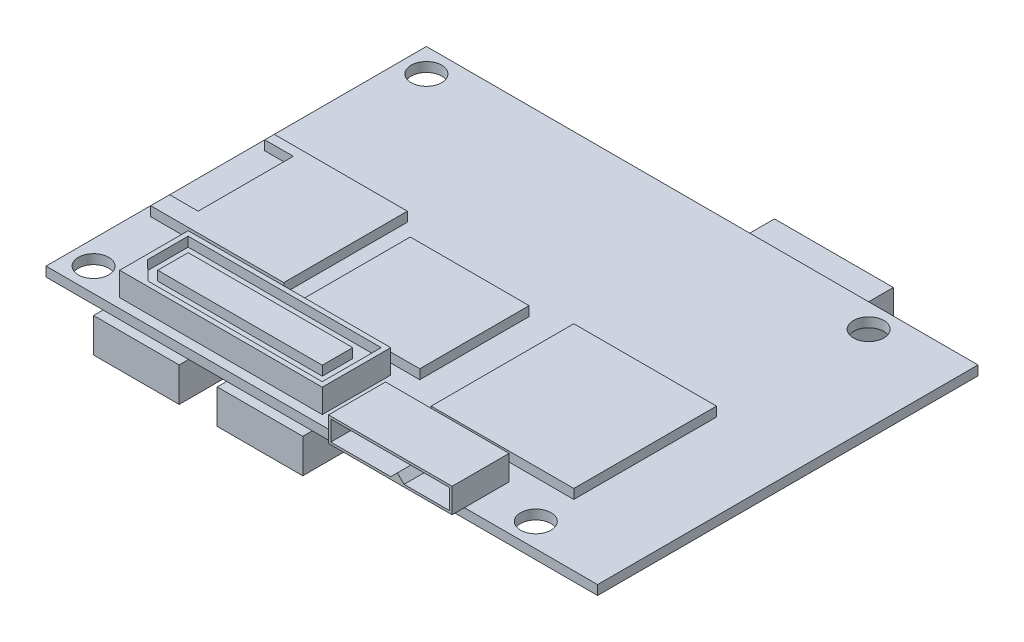
from build123d import *

# Parameters (mm, degrees)
SKETCH1_W            = 58
SKETCH1_H            = 40
BOSS_EXTRUDE1_DEPTH  = 1
SKETCH2_W            = 14
SKETCH2_H            = 13
BOSS_EXTRUDE2_DEPTH  = 1
SKETCH3_W            = 3
SKETCH3_H            = 10
CUT_EXTRUDE1_DEPTH   = 1
SKETCH4_W            = 12.5
SKETCH4_H            = 11.5
SKETCH4_W_2          = 15
SKETCH4_H_2          = 15
BOSS_EXTRUDE3_DEPTH  = 1
SKETCH5_W            = 13
SKETCH5_H            = 6
BOSS_EXTRUDE4_DEPTH  = 2.6
CUT_EXTRUDE2_DEPTH   = 5
SKETCH7_W            = 21.3
SKETCH7_H            = 7.2
BOSS_EXTRUDE5_DEPTH  = 2.5
SKETCH8_W            = 17.3
SKETCH8_H            = 3.2
CUT_EXTRUDE3_DEPTH   = 1
SKETCH9_R            = 1.6
CUT_EXTRUDE4_DEPTH   = 2
SKETCH10_W           = 9
SKETCH10_H           = 5
BOSS_EXTRUDE6_DEPTH  = 3.6
SKETCH11_W           = 12.5
SKETCH11_H           = 6.25
BOSS_EXTRUDE7_DEPTH  = 5
SKETCH12_W           = 10
SKETCH12_H           = 10
BOSS_EXTRUDE8_DEPTH  = 2.5
SKETCH13_R           = 1
SKETCH13_R_2         = 0.8
BOSS_EXTRUDE9_DEPTH  = 1
SKETCH14_R           = 0.15
BOSS_EXTRUDE10_DEPTH = 1


with BuildPart() as part:
    # Sketch1 → Boss-Extrude1 (new body)
    with BuildSketch(Plane(origin=(0, 0, 0), x_dir=(1, 0, 0), z_dir=(0, 1, 0))):
        Rectangle(SKETCH1_W, SKETCH1_H)
    extrude(amount=BOSS_EXTRUDE1_DEPTH)

    # Sketch2 → Boss-Extrude2 (add)
    with BuildSketch(Plane(origin=(0, 1, 0), x_dir=(1, 0, 0), z_dir=(0, 1, 0))):
        with Locations((-21, -3.5)):
            Rectangle(SKETCH2_W, SKETCH2_H)
    extrude(amount=BOSS_EXTRUDE2_DEPTH)

    # Sketch3 → Cut-Extrude1 (cut)
    with BuildSketch(Plane(origin=(0, 2, 0), x_dir=(1, 0, 0), z_dir=(0, 1, 0))):
        with Locations((-26.5, -3)):
            Rectangle(SKETCH3_W, SKETCH3_H)
    extrude(amount=-CUT_EXTRUDE1_DEPTH, mode=Mode.SUBTRACT)

    # Sketch4 → Boss-Extrude3 (add)
    with BuildSketch(Plane(origin=(0, 1, 0), x_dir=(1, 0, 0), z_dir=(0, 1, 0))):
        with Locations((-5.25, -4.95)):
            Rectangle(SKETCH4_W, SKETCH4_H)
        with Locations((12.5, -6)):
            Rectangle(SKETCH4_W_2, SKETCH4_H_2)
    extrude(amount=BOSS_EXTRUDE3_DEPTH)

    # Sketch5 → Boss-Extrude4 (add)
    with BuildSketch(Plane(origin=(0, 1, 0), x_dir=(1, 0, 0), z_dir=(0, 1, 0))):
        with Locations((8.5, -18.3)):
            Rectangle(SKETCH5_W, SKETCH5_H)
    extrude(amount=BOSS_EXTRUDE4_DEPTH)

    # Sketch6 → Cut-Extrude2 (cut)
    with BuildSketch(Plane.XY.offset(21.3)):
        Polygon((2.25, 3.35), (14.75, 3.35), (14.75, 1.25), (9.95, 1.25), (9.25, 1.95), (8.55, 1.25), (2.25, 1.25), align=None)
    extrude(amount=-CUT_EXTRUDE2_DEPTH, mode=Mode.SUBTRACT)

    # Sketch7 → Boss-Extrude5 (add)
    with BuildSketch(Plane(origin=(0, 1, 0), x_dir=(1, 0, 0), z_dir=(0, 1, 0))):
        with Locations((-11.6, -15.4)):
            Rectangle(SKETCH7_W, SKETCH7_H)
    extrude(amount=BOSS_EXTRUDE5_DEPTH)

    # Sketch8 → Cut-Extrude3 (cut)
    with BuildSketch(Plane(origin=(0, 3.5, 0), x_dir=(1, 0, 0), z_dir=(0, 1, 0))):
        Polygon((-21.75, -12.3), (-21.75, -16.586355197), (-19.749371343, -18.5), (-1.45, -18.5), (-1.45, -12.3), align=None)
        with Locations((-11.6, -15.4)):
            Rectangle(SKETCH8_W, SKETCH8_H, mode=Mode.SUBTRACT)
    extrude(amount=-CUT_EXTRUDE3_DEPTH, mode=Mode.SUBTRACT)

    # Sketch9 → Cut-Extrude4 (cut, through all)
    with BuildSketch(Plane(origin=(0, 1, 0), x_dir=(1, 0, 0), z_dir=(0, 1, 0))):
        with Locations((-26.5, 17.5)):
            Circle(SKETCH9_R)
        with Locations((20, 17.5)):
            Circle(SKETCH9_R)
        with Locations((20, -17.5)):
            Circle(SKETCH9_R)
        with Locations((-26.5, -17.5)):
            Circle(SKETCH9_R)
    extrude(amount=-CUT_EXTRUDE4_DEPTH, mode=Mode.SUBTRACT)

    # Sketch10 → Boss-Extrude6 (add)
    with BuildSketch(Plane.XZ):
        with Locations((-18.5, 18.5)):
            Rectangle(SKETCH10_W, SKETCH10_H)
        with Locations((-5.5, 18.5)):
            Rectangle(SKETCH10_W, SKETCH10_H)
        with Locations((-17.8, -18.5)):
            Rectangle(SKETCH10_W, SKETCH10_H)
        with Locations((-4.8, -18.5)):
            Rectangle(SKETCH10_W, SKETCH10_H)
    extrude(amount=BOSS_EXTRUDE6_DEPTH)

    # Sketch11 → Boss-Extrude7 (add)
    with BuildSketch(Plane.XZ):
        with Locations((10.25, -20.475)):
            Rectangle(SKETCH11_W, SKETCH11_H)
    extrude(amount=BOSS_EXTRUDE7_DEPTH)

    # Sketch12 → Boss-Extrude8 (add)
    with BuildSketch(Plane.XZ):
        with Locations((-18, 6.5)):
            Rectangle(SKETCH12_W, SKETCH12_H)
    extrude(amount=BOSS_EXTRUDE8_DEPTH)

    # Sketch13 → Boss-Extrude9 (add)
    with BuildSketch(Plane.XZ):
        with Locations((-26.5, 12.5)):
            Circle(SKETCH13_R)
        with Locations((-26.5, 12.5)):
            Circle(SKETCH13_R_2, mode=Mode.SUBTRACT)
        with Locations((-26.5, 4)):
            Circle(SKETCH13_R)
        with Locations((-26.5, 4)):
            Circle(SKETCH13_R_2, mode=Mode.SUBTRACT)
        with Locations((-26.5, -3.5)):
            Circle(SKETCH13_R)
        with Locations((-26.5, -3.5)):
            Circle(SKETCH13_R_2, mode=Mode.SUBTRACT)
    extrude(amount=BOSS_EXTRUDE9_DEPTH)

    # Sketch14 → Boss-Extrude10 (add)
    with BuildSketch(Plane.XZ):
        with Locations((-26.5, 12.5)):
            Circle(SKETCH14_R)
        with Locations((-26.5, 4)):
            Circle(SKETCH14_R)
        with Locations((-26.5, -3.5)):
            Circle(SKETCH14_R)
    extrude(amount=BOSS_EXTRUDE10_DEPTH)


solid = part.part
